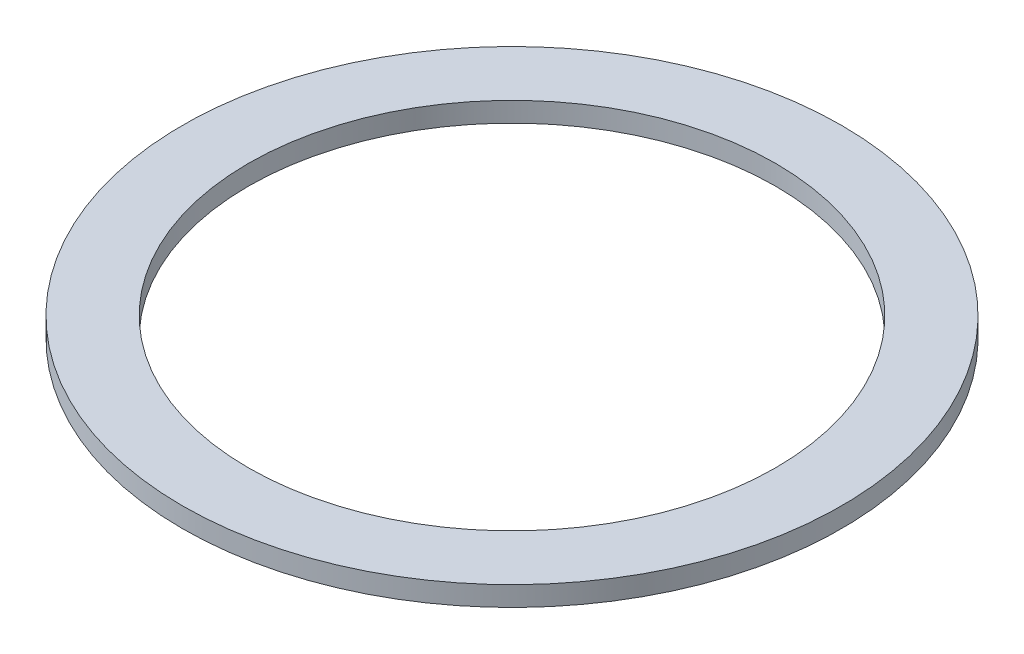
from build123d import *

# Parameters (mm, degrees)
SKETCH1_R           = 500
SKETCH1_R_2         = 400
BOSS_EXTRUDE1_DEPTH = 30


with BuildPart() as part:
    # Sketch1 → Boss-Extrude1 (new body)
    with BuildSketch(Plane(origin=(0, 0, 0), x_dir=(1, 0, 0), z_dir=(0, 1, 0))):
        Circle(SKETCH1_R)
        Circle(SKETCH1_R_2, mode=Mode.SUBTRACT)
    extrude(amount=BOSS_EXTRUDE1_DEPTH)


solid = part.part
